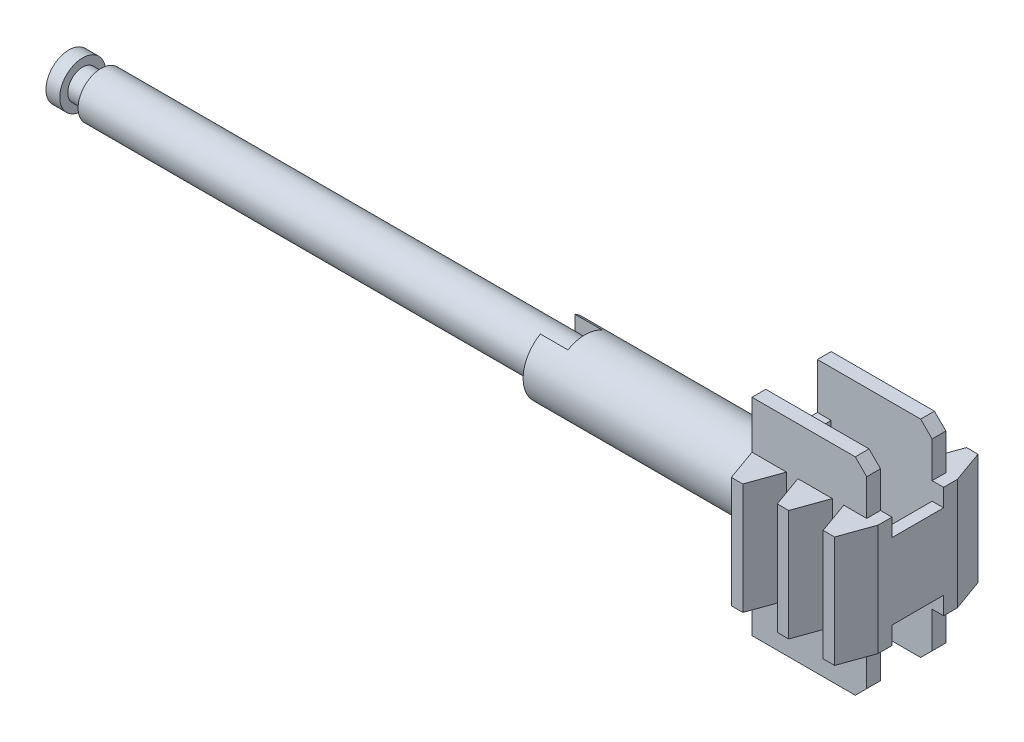
from build123d import *

# Parameters (mm, degrees)
SKETCH1_R            = 2
BOSS_EXTRUDE1_DEPTH  = 1.2
SKETCH2_R            = 1.3
BOSS_EXTRUDE2_DEPTH  = 1.6
SKETCH3_R            = 2
BOSS_EXTRUDE3_DEPTH  = 42.2
SKETCH4_R            = 3
BOSS_EXTRUDE4_DEPTH  = 18
BOSS_EXTRUDE7_DEPTH  = 2.4
SKETCH6_W            = 6.9
SKETCH6_H            = 10
BOSS_EXTRUDE8_DEPTH  = 1.2
BOSS_EXTRUDE9_DEPTH  = 10
CHAMFER1_SIZE        = 1
BOSS_EXTRUDE10_DEPTH = 4.85
SKETCH9_W            = 6.9
SKETCH9_H            = 9.7
BOSS_EXTRUDE11_DEPTH = 1
SKETCH11_W           = 4.5
SKETCH11_H           = 1.55
CUT_EXTRUDE1_DEPTH   = 1


with BuildPart() as part:
    # Sketch1 → Boss-Extrude1 (new body)
    with BuildSketch(Plane(origin=(0, 0, 0), x_dir=(0, 0, -1), z_dir=(1, 0, 0))):
        Circle(SKETCH1_R)
    extrude(amount=BOSS_EXTRUDE1_DEPTH)

    # Sketch2 → Boss-Extrude2 (add)
    with BuildSketch(Plane(origin=(1.2, 0, 0), x_dir=(0, 0, -1), z_dir=(1, 0, 0))):
        Circle(SKETCH2_R)
    extrude(amount=BOSS_EXTRUDE2_DEPTH)

    # Sketch3 → Boss-Extrude3 (add)
    with BuildSketch(Plane(origin=(2.8, 0, 0), x_dir=(0, 0, -1), z_dir=(1, 0, 0))):
        Circle(SKETCH3_R)
    extrude(amount=BOSS_EXTRUDE3_DEPTH)

    # Sketch4 → Boss-Extrude4 (add)
    with BuildSketch(Plane(origin=(45, 0, 0), x_dir=(0, 0, -1), z_dir=(1, 0, 0))):
        Circle(SKETCH4_R)
    extrude(amount=BOSS_EXTRUDE4_DEPTH)

    # Sketch5 → Boss-Extrude7 (add)
    with BuildSketch(Plane.ZY.offset(-45)):
        with BuildLine():
            ThreePointArc((3, 0), (2.598076211, 1.5), (1.5, 2.598076211))
            Line((1.5, 2.598076211), (1.5, -2.598076211))
            ThreePointArc((1.5, -2.598076211), (2.598076211, -1.5), (3, 0))
        make_face()
        with BuildLine():
            Line((-1.5, -2.598076211), (-1.5, 2.598076211))
            ThreePointArc((-1.5, 2.598076211), (-3, 0), (-1.5, -2.598076211))
        make_face()
    extrude(amount=BOSS_EXTRUDE7_DEPTH)

    # Sketch6 → Boss-Extrude8 (add)
    with BuildSketch(Plane(origin=(63, 0, 0), x_dir=(0, 0, -1), z_dir=(1, 0, 0))):
        Rectangle(SKETCH6_W, SKETCH6_H)
    extrude(amount=BOSS_EXTRUDE8_DEPTH)

    # Sketch7 → Boss-Extrude9 (add)
    with BuildSketch(Plane.ZY.offset(-63)):
        Polygon((-3.45, 5), (-3.45, 9), (-2.25, 9), (-2.25, -9), (-3.45, -9), (-3.45, -5), align=None)
        Polygon((3.45, 9), (2.25, 9), (2.25, -9), (3.45, -9), (3.45, -5), (3.45, 5), align=None)
    extrude(amount=-BOSS_EXTRUDE9_DEPTH)

    # Chamfer1
    chamfer1_edges = [part.edges().sort_by_distance(p)[0] for p in [
        (73, 9, -2.85),
        (73, -9, -2.85),
        (73, -9, 2.85),
        (73, 9, 2.85),
    ]]
    chamfer(chamfer1_edges, length=CHAMFER1_SIZE)

    # Sketch8 → Boss-Extrude10 (add, symmetric)
    with BuildSketch(Plane(origin=(0, 0, 0), x_dir=(1, 0, 0), z_dir=(0, 1, 0))):
        Polygon((63, 3.45), (66, 3.45), (65, 6.25), (64, 6.25), align=None)
        Polygon((68, 6.25), (69, 6.25), (70, 3.45), (67, 3.45), align=None)
        Polygon((72, 6.25), (73, 6.25), (74, 3.45), (71, 3.45), align=None)
    boss_extrude10 = extrude(amount=BOSS_EXTRUDE10_DEPTH, both=True)

    # Mirror1: Boss-Extrude10 across plane
    add(boss_extrude10.mirror(Plane.XY))

    # Sketch9 → Boss-Extrude11 (add)
    with BuildSketch(Plane(origin=(73, 0, 0), x_dir=(0, 0, -1), z_dir=(1, 0, 0))):
        Rectangle(SKETCH9_W, SKETCH9_H)
    extrude(amount=BOSS_EXTRUDE11_DEPTH)

    # Sketch11 → Cut-Extrude1 (cut)
    with BuildSketch(Plane(origin=(74, 0, 0), x_dir=(0, 0, -1), z_dir=(1, 0, 0))):
        with Locations((0, -4.075)):
            Rectangle(SKETCH11_W, SKETCH11_H)
        with Locations((0, 4.075)):
            Rectangle(SKETCH11_W, SKETCH11_H)
    extrude(amount=-CUT_EXTRUDE1_DEPTH, mode=Mode.SUBTRACT)


solid = part.part
